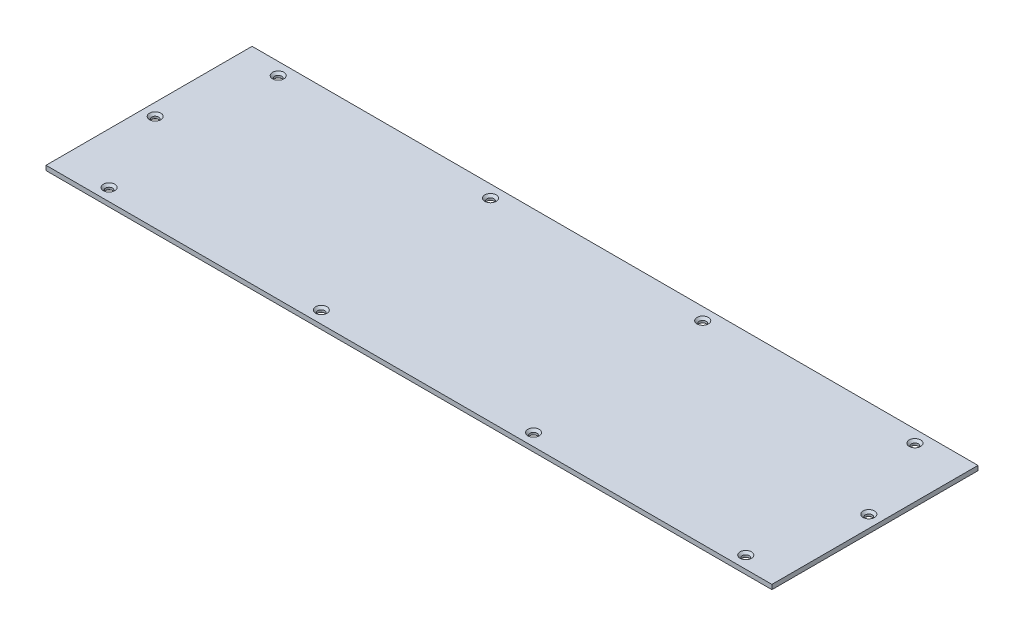
from build123d import *

# Parameters (mm, degrees)
SKETCH_2_W                  = 472
SKETCH_2_H                  = 134
EXTRUDE_1_DEPTH             = 3
HOLE_WIZARD_M41_AT_2_COUNT  = 2
HOLE_WIZARD_M41_AT_2_PITCH  = 138
HOLE_WIZARD_M41_AT_3_COUNT  = 2
HOLE_WIZARD_M41_AT_3_PITCH  = 276
HOLE_WIZARD_M41_AT_4_COUNT  = 2
HOLE_WIZARD_M41_AT_4_PITCH  = 414
HOLE_WIZARD_M41_AT_5_COUNT  = 2
HOLE_WIZARD_M41_AT_5_PITCH  = 442.431915666
HOLE_WIZARD_M41_AT_6_COUNT  = 2
HOLE_WIZARD_M41_AT_6_PITCH  = 438.187174618
HOLE_WIZARD_M41_AT_7_COUNT  = 2
HOLE_WIZARD_M41_AT_7_PITCH  = 307.538615462
HOLE_WIZARD_M41_AT_8_COUNT  = 2
HOLE_WIZARD_M41_AT_8_PITCH  = 187.723200484
HOLE_WIZARD_M41_AT_9_COUNT  = 2
HOLE_WIZARD_M41_AT_9_PITCH  = 118.270875536
HOLE_WIZARD_M41_AT_10_COUNT = 2
HOLE_WIZARD_M41_AT_10_PITCH = 65.253352404


with BuildPart() as part:
    # Эскиз2 → Бобышка-Вытянуть1 (new body)
    with BuildSketch(Plane(origin=(0, 0, 0), x_dir=(1, 0, 0), z_dir=(0, 1, 0))):
        with Locations((236, 67)):
            Rectangle(SKETCH_2_W, SKETCH_2_H)
    extrude(amount=EXTRUDE_1_DEPTH)

    # Эскиз3 → Зенковка для винта с потайной головкой M41 (revolve, cut)
    with BuildSketch(Plane(origin=(25, 3, -126), x_dir=(0, 0, 1), z_dir=(1, 0, 0))):
        Polygon((0, 0), (0, 3), (2.4, 3), (2.25, 2.85), (2.25, 1.45), (3.7, 0), align=None)
    hole_wizard_m41 = revolve(axis=Axis((25, 9.35, -126), (0, -1, 0)), mode=Mode.SUBTRACT)

    # Зенковка для винта с потайной головкой M41 at 2: Зенковка для винта с потайной головкой M41 ×2
    with Locations(*[(i * HOLE_WIZARD_M41_AT_2_PITCH, 0, 0) for i in range(1, HOLE_WIZARD_M41_AT_2_COUNT)]):
        add(hole_wizard_m41, mode=Mode.SUBTRACT)

    # Зенковка для винта с потайной головкой M41 at 3: Зенковка для винта с потайной головкой M41 ×2
    with Locations(*[(i * HOLE_WIZARD_M41_AT_3_PITCH, 0, 0) for i in range(1, HOLE_WIZARD_M41_AT_3_COUNT)]):
        add(hole_wizard_m41, mode=Mode.SUBTRACT)

    # Зенковка для винта с потайной головкой M41 at 4: Зенковка для винта с потайной головкой M41 ×2
    with Locations(*[(i * HOLE_WIZARD_M41_AT_4_PITCH, 0, 0) for i in range(1, HOLE_WIZARD_M41_AT_4_COUNT)]):
        add(hole_wizard_m41, mode=Mode.SUBTRACT)

    # Зенковка для винта с потайной головкой M41 at 5: Зенковка для винта с потайной головкой M41 ×2
    with Locations(*[Vector(0.992243065, 0, 0.124312912) * (i * HOLE_WIZARD_M41_AT_5_PITCH) for i in range(1, HOLE_WIZARD_M41_AT_5_COUNT)]):
        add(hole_wizard_m41, mode=Mode.SUBTRACT)

    # Зенковка для винта с потайной головкой M41 at 6: Зенковка для винта с потайной головкой M41 ×2
    with Locations(*[Vector(0.963058767, 0, 0.269291314) * (i * HOLE_WIZARD_M41_AT_6_PITCH) for i in range(1, HOLE_WIZARD_M41_AT_6_COUNT)]):
        add(hole_wizard_m41, mode=Mode.SUBTRACT)

    # Зенковка для винта с потайной головкой M41 at 7: Зенковка для винта с потайной головкой M41 ×2
    with Locations(*[Vector(0.923461269, 0, 0.383691654) * (i * HOLE_WIZARD_M41_AT_7_PITCH) for i in range(1, HOLE_WIZARD_M41_AT_7_COUNT)]):
        add(hole_wizard_m41, mode=Mode.SUBTRACT)

    # Зенковка для винта с потайной головкой M41 at 8: Зенковка для винта с потайной головкой M41 ×2
    with Locations(*[Vector(0.777740842, 0, 0.628585064) * (i * HOLE_WIZARD_M41_AT_8_PITCH) for i in range(1, HOLE_WIZARD_M41_AT_8_COUNT)]):
        add(hole_wizard_m41, mode=Mode.SUBTRACT)

    # Зенковка для винта с потайной головкой M41 at 9: Зенковка для винта с потайной головкой M41 ×2
    with Locations(*[Vector(0.067641336, 0, 0.997709702) * (i * HOLE_WIZARD_M41_AT_9_PITCH) for i in range(1, HOLE_WIZARD_M41_AT_9_COUNT)]):
        add(hole_wizard_m41, mode=Mode.SUBTRACT)

    # Зенковка для винта с потайной головкой M41 at 10: Зенковка для винта с потайной головкой M41 ×2
    with Locations(*[Vector(-0.260523013, 0, 0.965467638) * (i * HOLE_WIZARD_M41_AT_10_PITCH) for i in range(1, HOLE_WIZARD_M41_AT_10_COUNT)]):
        add(hole_wizard_m41, mode=Mode.SUBTRACT)


solid = part.part
